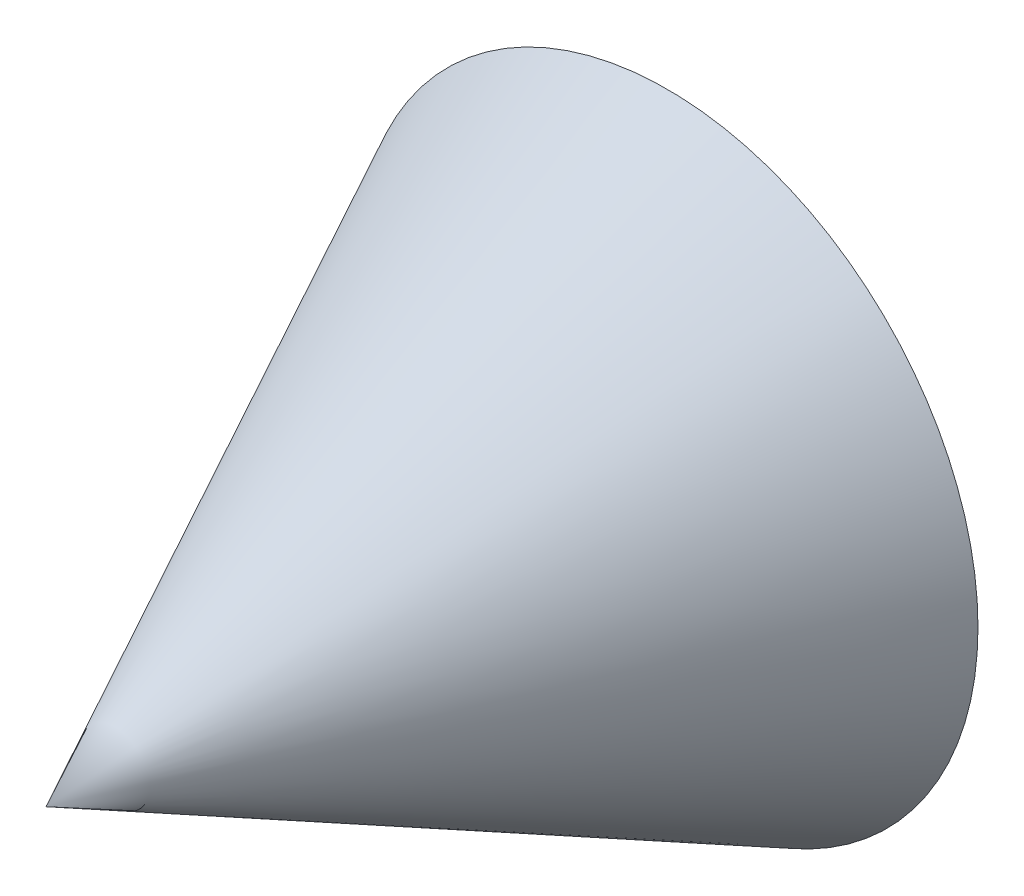
from build123d import *

# Parameters (mm, degrees)
ESBO_O1_R = 50


with BuildPart() as part:
    # Esboço1 → Loft1 section 0
    with BuildSketch(Plane.XY, mode=Mode.PRIVATE) as loft1_s0:
        Circle(ESBO_O1_R)
    loft([loft1_s0.sketch, Vertex(0, 0, 100)])


solid = part.part
